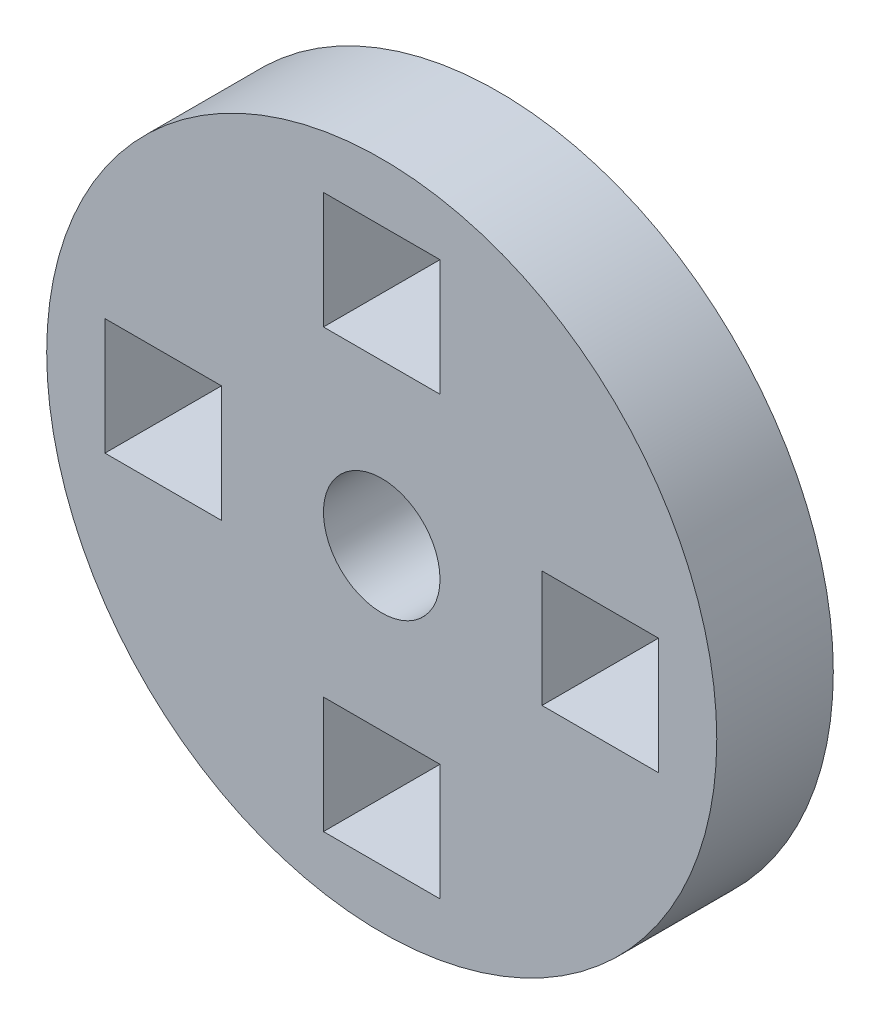
from build123d import *

# Parameters (mm, degrees)
SKETCH1_R           = 11.5
SKETCH1_W           = 4
SKETCH1_H           = 4
BOSS_EXTRUDE1_DEPTH = 4
SKETCH2_R           = 2
CUT_EXTRUDE1_DEPTH  = 4


with BuildPart() as part:
    # Sketch1 → Boss-Extrude1 (new body)
    with BuildSketch(Plane.XY):
        Circle(SKETCH1_R)
        with Locations((0, 7.5)):
            Rectangle(SKETCH1_W, SKETCH1_H, mode=Mode.SUBTRACT)
        with Locations((7.5, 0)):
            Rectangle(SKETCH1_W, SKETCH1_H, mode=Mode.SUBTRACT)
        with Locations((0, -7.5)):
            Rectangle(SKETCH1_W, SKETCH1_H, mode=Mode.SUBTRACT)
        with Locations((-7.5, 0)):
            Rectangle(SKETCH1_W, SKETCH1_H, mode=Mode.SUBTRACT)
    extrude(amount=BOSS_EXTRUDE1_DEPTH)

    # Sketch2 → Cut-Extrude1 (cut)
    with BuildSketch(Plane.XY.offset(4)):
        Circle(SKETCH2_R)
    extrude(amount=-CUT_EXTRUDE1_DEPTH, mode=Mode.SUBTRACT)


solid = part.part
